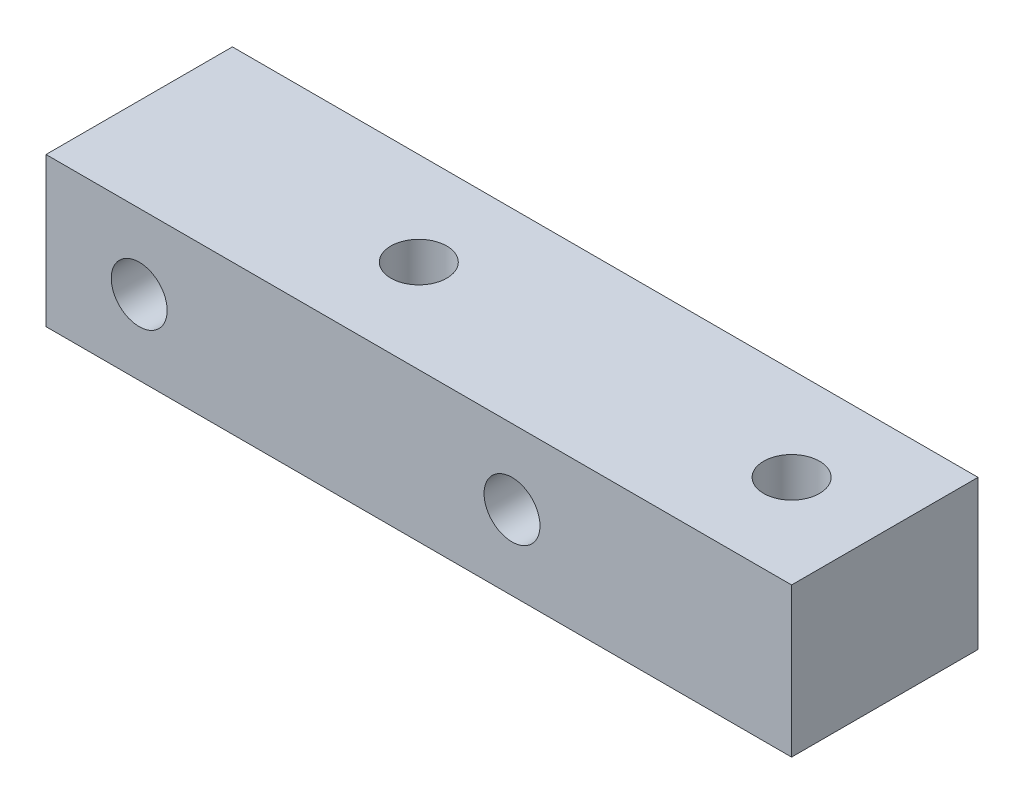
from build123d import *

# Parameters (mm, degrees)
SKETCH_1_W          = 40
SKETCH_1_H          = 8
SKETCH_1_R          = 1.5
EXTRUDE_1_DEPTH     = 10
SKETCH_2_R          = 1.5
CUT_EXTRUDE_5_DEPTH = 9


with BuildPart() as part:
    # 草图1 → 凸台-拉伸1 (new body)
    with BuildSketch(Plane.XY):
        Rectangle(SKETCH_1_W, SKETCH_1_H)
        with Locations((-15, 0)):
            Circle(SKETCH_1_R, mode=Mode.SUBTRACT)
        with Locations((5, 0)):
            Circle(SKETCH_1_R, mode=Mode.SUBTRACT)
    extrude(amount=EXTRUDE_1_DEPTH)

    # 草图2 → 切除-拉伸5 (cut, through all)
    with BuildSketch(Plane(origin=(0, 4, 0), x_dir=(1, 0, 0), z_dir=(0, 1, 0))):
        with Locations((15, -5)):
            Circle(SKETCH_2_R)
        with Locations((-5, -5)):
            Circle(SKETCH_2_R)
    extrude(amount=-CUT_EXTRUDE_5_DEPTH, mode=Mode.SUBTRACT)


solid = part.part
